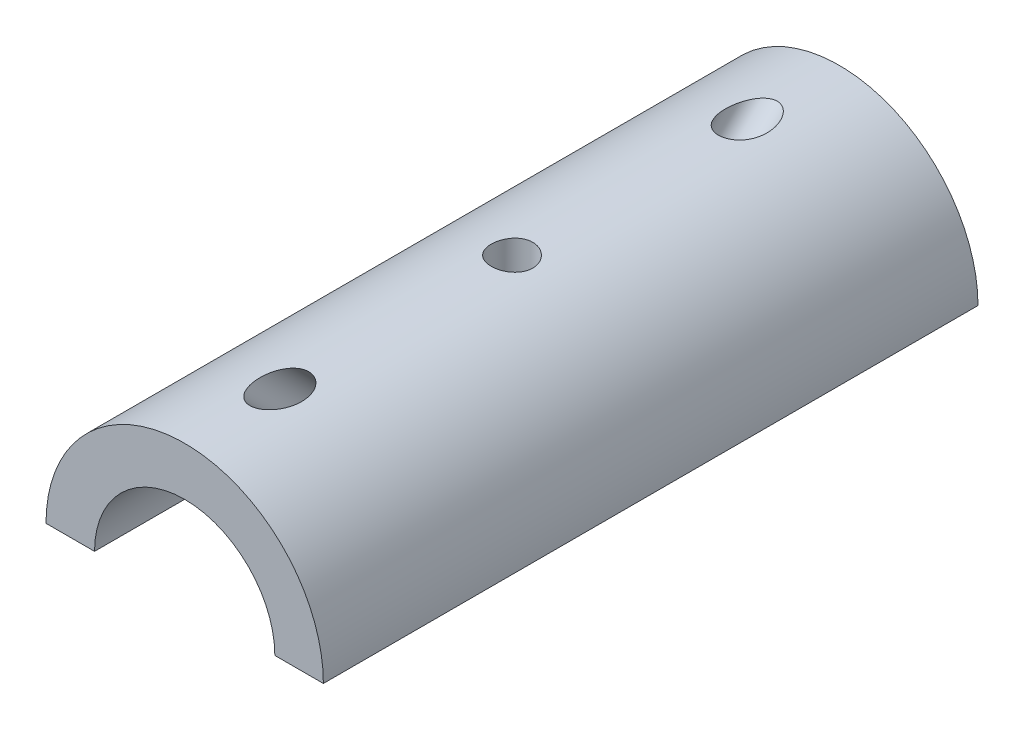
from build123d import *

# Parameters (mm, degrees)
BOSS_EXTRUDE1_DEPTH     = 47.2
CUT_EXTRUDE1_DEPTH      = 50.273116402
CUT_EXTRUDE1_DEPTH_BACK = 50.273116402
SKETCH3_R               = 1.5
CUT_EXTRUDE3_DEPTH      = 51.597430898
CUT_EXTRUDE3_DEPTH_BACK = 51.597430898
SKETCH7_R               = 1.5
CUT_EXTRUDE4_DEPTH      = 37.999869057
CUT_EXTRUDE4_DEPTH_BACK = 37.999869057
SKETCH10_R              = 1.5


with BuildPart() as part:
    # Sketch1 → Boss-Extrude1 (new body)
    with BuildSketch(Plane.XY):
        with BuildLine():
            Line((6.5, 0), (10, 0))
            ThreePointArc((10, 0), (0, 10), (-10, 0))
            Line((-10, 0), (-6.5, 0))
            ThreePointArc((-6.5, 0), (0, 6.5), (6.5, 0))
        make_face()
    extrude(amount=BOSS_EXTRUDE1_DEPTH)

    # Sketch3 → Cut-Extrude1 (cut, two sides: drawn at the far end of the back side and taken through both)
    with BuildSketch(Plane(origin=(0, 0, 0), x_dir=(1, 0, 0), z_dir=(0, 1, 0)).offset(-CUT_EXTRUDE1_DEPTH_BACK)):
        with Locations(Location((0, -23.6, 0), (0, 0, 270))):
            Circle(SKETCH3_R)
    extrude(amount=CUT_EXTRUDE1_DEPTH + CUT_EXTRUDE1_DEPTH_BACK, mode=Mode.SUBTRACT)

    # Sketch7 → Cut-Extrude3 (cut, two sides: drawn at the far end of the back side and taken through both)
    with BuildSketch(Plane(origin=(0, 1.7, -1.7), x_dir=(0, 0.7071067811865389, 0.7071067811865561), z_dir=(0, 0.7071067811865561, -0.7071067811865389)).offset(-CUT_EXTRUDE3_DEPTH_BACK)):
        with Locations((11.737972568, 0)):
            Circle(SKETCH7_R)
    extrude(amount=CUT_EXTRUDE3_DEPTH + CUT_EXTRUDE3_DEPTH_BACK, mode=Mode.SUBTRACT)

    # Sketch10 → Cut-Extrude4 (cut, two sides: drawn at the far end of the back side and taken through both)
    with BuildSketch(Plane(origin=(0, 25.189187146, 25.189187146), x_dir=(0, -0.7071067811865488, 0.7071067811865464), z_dir=(0, 0.7071067811865464, 0.7071067811865488)).offset(-CUT_EXTRUDE4_DEPTH_BACK)):
        with Locations((21.480754463, 0)):
            Circle(SKETCH10_R)
    extrude(amount=CUT_EXTRUDE4_DEPTH + CUT_EXTRUDE4_DEPTH_BACK, mode=Mode.SUBTRACT)


solid = part.part
